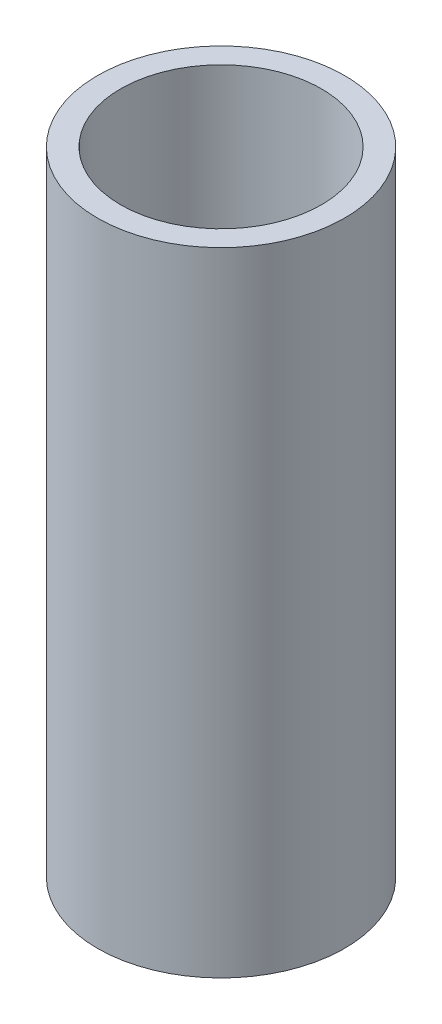
from build123d import *

# Parameters (mm, degrees)
SKETCH3_R           = 37.5
SKETCH3_R_2         = 30.5
BOSS_EXTRUDE1_DEPTH = 192


with BuildPart() as part:
    # Sketch3 → Boss-Extrude1 (new body)
    with BuildSketch(Plane(origin=(0, 0, 0), x_dir=(1, 0, 0), z_dir=(0, 1, 0))):
        Circle(SKETCH3_R)
        Circle(SKETCH3_R_2, mode=Mode.SUBTRACT)
    extrude(amount=BOSS_EXTRUDE1_DEPTH)


solid = part.part
